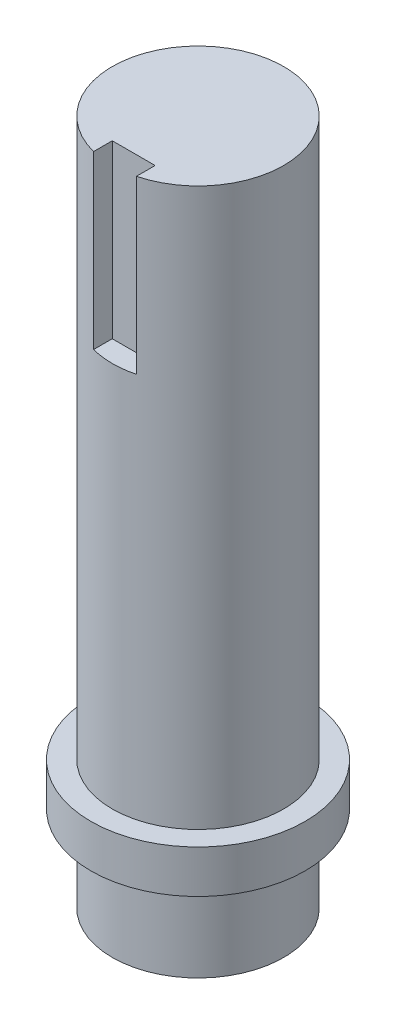
from build123d import *

# Parameters (mm, degrees)
SKETCH1_R           = 15.875
BOSS_EXTRUDE1_DEPTH = 101.6
SKETCH2_OUTSIDE_W   = 55.966
SKETCH2_OUTSIDE_H   = 55.966
SKETCH2_OUTSIDE_R   = 12.7
CUT_EXTRUDE1_DEPTH  = 82.55
SKETCH3_W           = 6.35
SKETCH3_H           = 6.35
CUT_EXTRUDE2_DEPTH  = 25.4
SKETCH4_OUTSIDE_W   = 55.966
SKETCH4_OUTSIDE_H   = 55.966
SKETCH4_OUTSIDE_R   = 12.7
CUT_EXTRUDE3_DEPTH  = 12.7


with BuildPart() as part:
    # Sketch1 → Boss-Extrude1 (new body)
    with BuildSketch(Plane(origin=(0, 0, 0), x_dir=(1, 0, 0), z_dir=(0, 1, 0))):
        with Locations(Location((0, 0, 0), (0, 0, 270))):  # turned: the seam where the file's is
            Circle(SKETCH1_R)
    extrude(amount=BOSS_EXTRUDE1_DEPTH)

    # Sketch2 outside → Cut-Extrude1 (cut)
    with BuildSketch(Plane(origin=(0, 101.6, 0), x_dir=(1, 0, 0), z_dir=(0, 1, 0))):
        Rectangle(SKETCH2_OUTSIDE_W, SKETCH2_OUTSIDE_H)
        with Locations(Location((0, 0, 0), (0, 0, 270))):  # turned: the seam where the file's is
            Circle(SKETCH2_OUTSIDE_R, mode=Mode.SUBTRACT)
    extrude(amount=-CUT_EXTRUDE1_DEPTH, mode=Mode.SUBTRACT)

    # Sketch3 → Cut-Extrude2 (cut)
    with BuildSketch(Plane(origin=(0, 101.6, 0), x_dir=(1, 0, 0), z_dir=(0, 1, 0))):
        with Locations((0, -12.7)):
            Rectangle(SKETCH3_W, SKETCH3_H)
    extrude(amount=-CUT_EXTRUDE2_DEPTH, mode=Mode.SUBTRACT)

    # Sketch4 outside → Cut-Extrude3 (cut)
    with BuildSketch(Plane.XZ):
        Rectangle(SKETCH4_OUTSIDE_W, SKETCH4_OUTSIDE_H)
        with Locations(Location((0, 0, 0), (0, 0, 90))):  # turned: the seam where the file's is
            Circle(SKETCH4_OUTSIDE_R, mode=Mode.SUBTRACT)
    extrude(amount=-CUT_EXTRUDE3_DEPTH, mode=Mode.SUBTRACT)


solid = part.part
